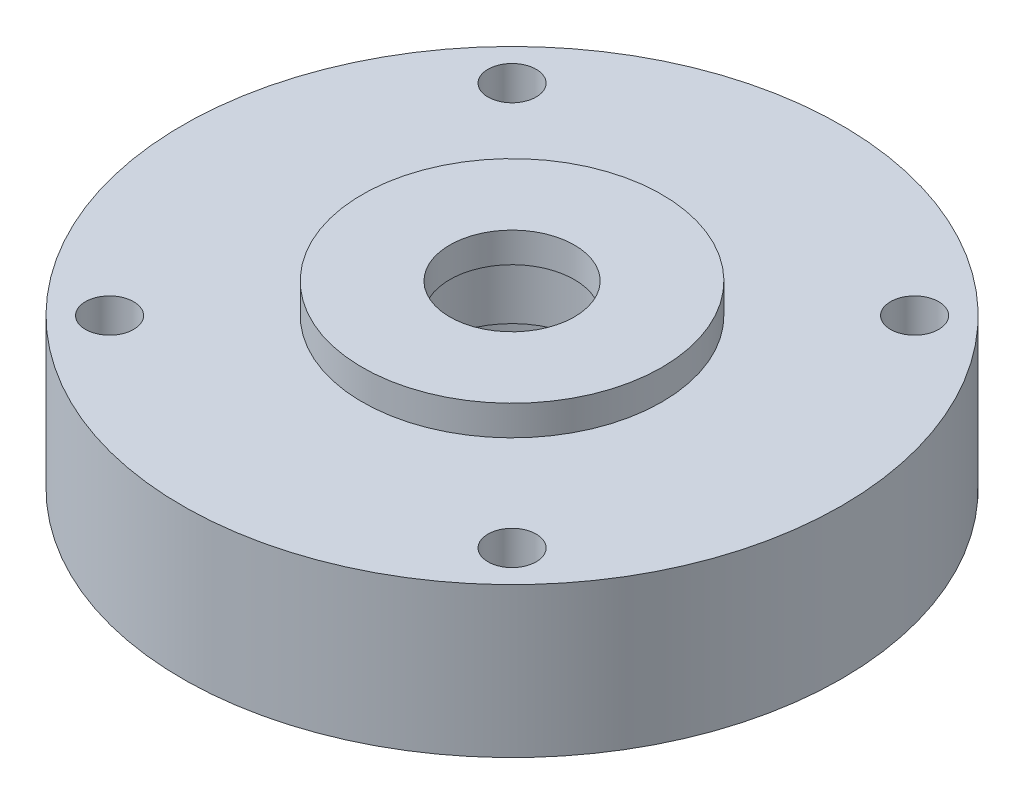
from build123d import *

# Parameters (mm, degrees)
F_10_CLEARANCE_HOLE1_D = 5.1054


with BuildPart() as part:
    # Sketch1 → Revolve1 (revolve)
    with BuildSketch(Plane.XY):
        Polygon((-15.875, 19.05), (-6.604, 19.05), (-6.604, 15.875), (-7.9375, 15.875), (-7.9375, 9.525), (-15.0125, 9.525), (-15.0125, 0), (-20.6375, 0), (-20.6375, 3.1369), (-25.4, 3.1369), (-25.4, 0), (-34.925, 0), (-34.925, 15.875), (-15.875, 15.875), align=None)
    revolve(axis=Axis((0, 0, 0), (0, 1, 0)))

    # #10 Clearance Hole1 (through all)
    with Locations(Plane(origin=(0, 15.875, 0), x_dir=(1, 0, 0), z_dir=(0, 1, 0))):
        with Locations((-21.328108288, 21.328108288), (21.328108288, 21.328108288), (21.328108288, -21.328108288), (-21.328108288, -21.328108288)):
            Hole(F_10_CLEARANCE_HOLE1_D / 2)


solid = part.part
